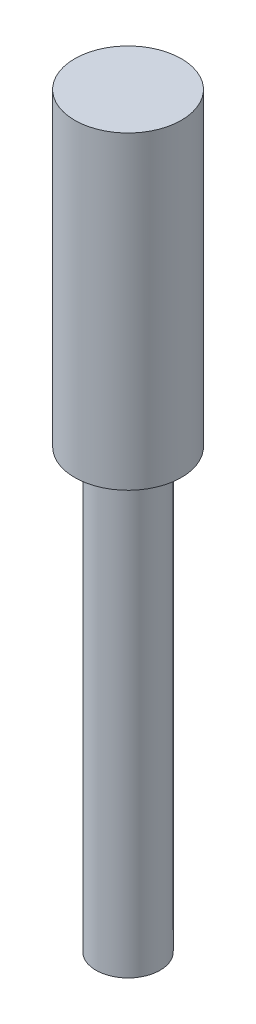
from build123d import *

# Parameters (mm, degrees)
SKETCH1_R           = 5
BOSS_EXTRUDE1_DEPTH = 70
SKETCH2_R           = 5
SKETCH2_R_2         = 3
CUT_EXTRUDE1_DEPTH  = 41


with BuildPart() as part:
    # Sketch1 → Boss-Extrude1 (new body)
    with BuildSketch(Plane(origin=(0, 0, 0), x_dir=(1, 0, 0), z_dir=(0, 1, 0))):
        Circle(SKETCH1_R)
    extrude(amount=BOSS_EXTRUDE1_DEPTH)

    # Sketch2 → Cut-Extrude1 (cut)
    with BuildSketch(Plane(origin=(0, 0, 0), x_dir=(-1, 0, 0), z_dir=(0, -1, 0))):
        Circle(SKETCH2_R)
        Circle(SKETCH2_R_2, mode=Mode.SUBTRACT)
    extrude(amount=-CUT_EXTRUDE1_DEPTH, mode=Mode.SUBTRACT)


solid = part.part
